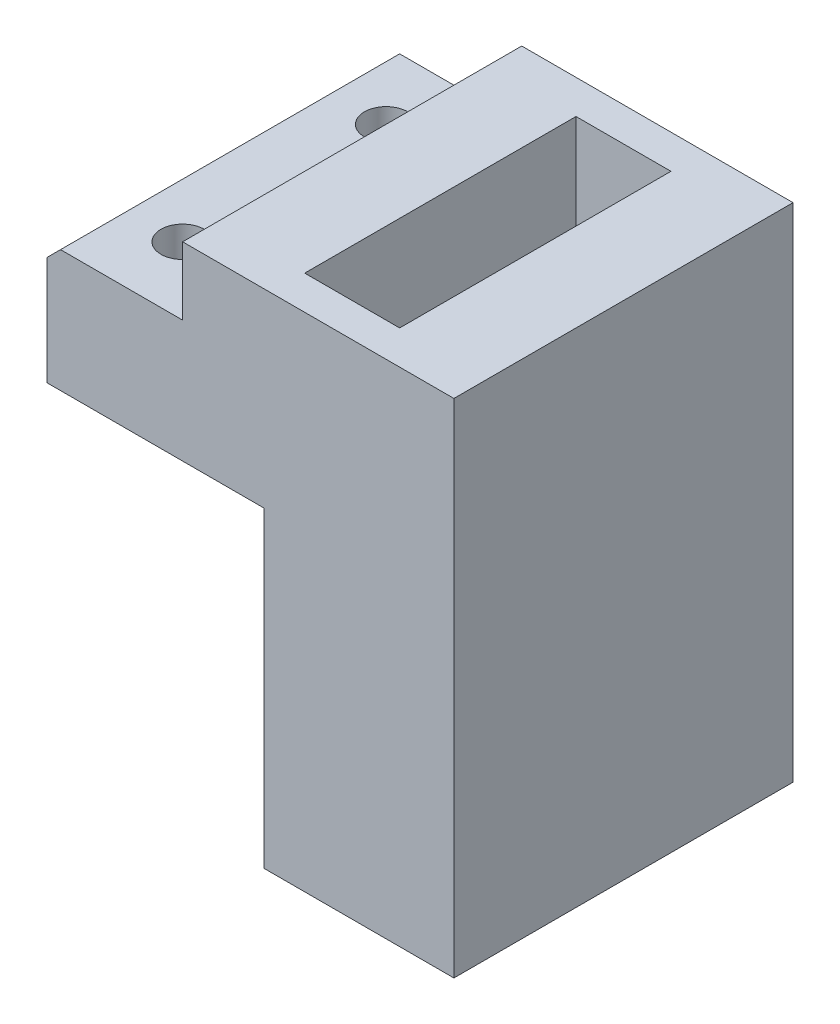
from build123d import *

# Parameters (mm, degrees)
SKETCH1_W                  = 30
SKETCH1_H                  = 25
BOSS_EXTRUDE1_DEPTH        = 14
F_3_2_3_2_DIAMETER_HOLE1_D = 3.2
SKETCH5_W                  = 7
SKETCH5_H                  = 20
CUT_EXTRUDE1_DEPTH         = 10
SKETCH6_W                  = 10
SKETCH6_H                  = 25
CUT_EXTRUDE2_DEPTH         = 5
CHAMFER1_SIZE              = 1
SKETCH7_W                  = 14
SKETCH7_H                  = 25
BOSS_EXTRUDE2_DEPTH        = 23


with BuildPart() as part:
    # Sketch1 → Boss-Extrude1 (new body)
    with BuildSketch(Plane(origin=(0, 0, 0), x_dir=(1, 0, 0), z_dir=(0, 1, 0))):
        with Locations((15, 0)):
            Rectangle(SKETCH1_W, SKETCH1_H)
    extrude(amount=BOSS_EXTRUDE1_DEPTH)

    # Ø3.2 (3.2) Diameter Hole1 (through all)
    with Locations(Plane(origin=(0, 14, 0), x_dir=(1, 0, 0), z_dir=(0, 1, 0))):
        with Locations((5, 7.5), (5, -7.5)):
            Hole(F_3_2_3_2_DIAMETER_HOLE1_D / 2)

    # Sketch5 → Cut-Extrude1 (cut)
    with BuildSketch(Plane(origin=(0, 14, 0), x_dir=(1, 0, 0), z_dir=(0, 1, 0))):
        with Locations((20, 0)):
            Rectangle(SKETCH5_W, SKETCH5_H)
    extrude(amount=-CUT_EXTRUDE1_DEPTH, mode=Mode.SUBTRACT)

    # Sketch6 → Cut-Extrude2 (cut)
    with BuildSketch(Plane(origin=(0, 14, 0), x_dir=(1, 0, 0), z_dir=(0, 1, 0))):
        with Locations((5, 0)):
            Rectangle(SKETCH6_W, SKETCH6_H)
    extrude(amount=-CUT_EXTRUDE2_DEPTH, mode=Mode.SUBTRACT)

    # Chamfer1
    chamfer1_edges = [part.edges().sort_by_distance(p)[0] for p in [
        (0, 9, 0),
    ]]
    chamfer(chamfer1_edges, length=CHAMFER1_SIZE)

    # Sketch7 → Boss-Extrude2 (add)
    with BuildSketch(Plane.XZ):
        with Locations((23, 0)):
            Rectangle(SKETCH7_W, SKETCH7_H)
    extrude(amount=BOSS_EXTRUDE2_DEPTH)


solid = part.part
